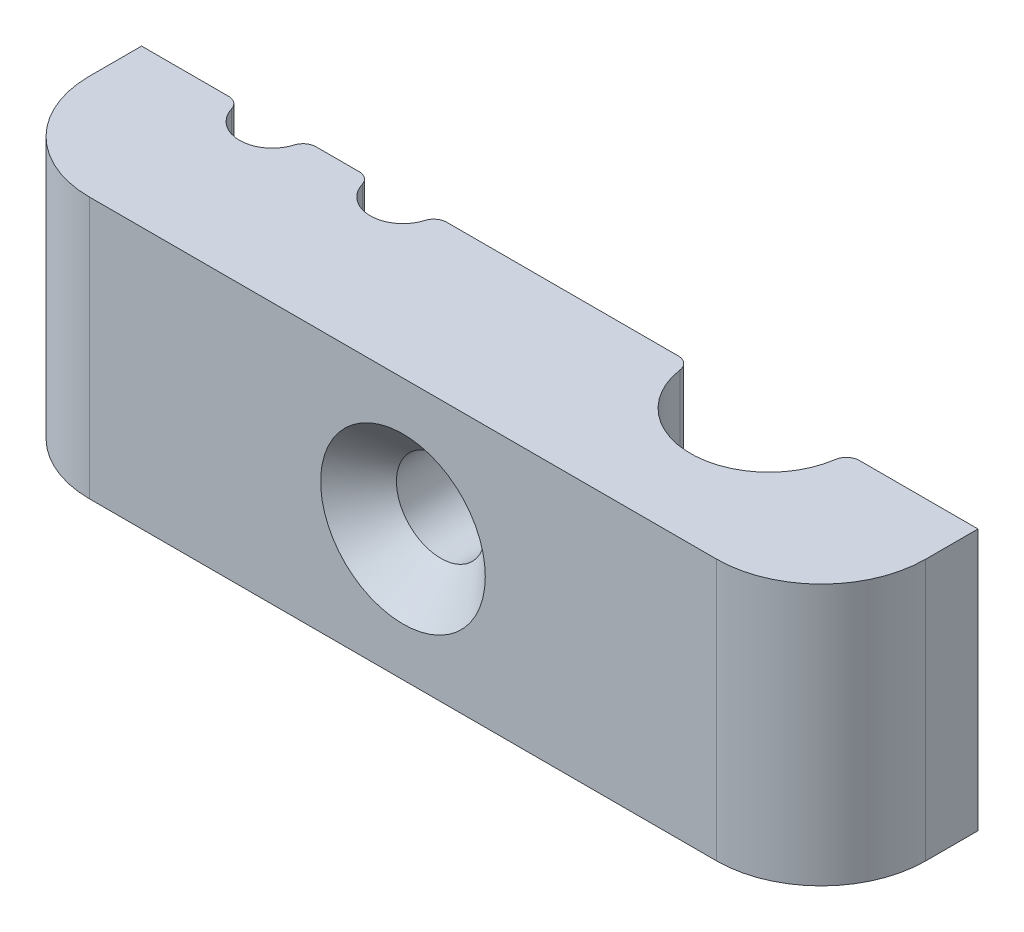
from build123d import *

# Parameters (mm, degrees)
SKETCH1_W               = 32
SKETCH1_H               = 10
BOSS_EXTRUDE1_DEPTH     = 6
FILLET1_R               = 4
SKETCH3_R               = 1.25
SKETCH3_R_2             = 3
CUT_EXTRUDE1_DEPTH      = 6
CUT_EXTRUDE1_DEPTH_BACK = 6
FILLET2_R               = 0.5


with BuildPart() as part:
    # Sketch1 → Boss-Extrude1 (new body)
    with BuildSketch(Plane.XY):
        Rectangle(SKETCH1_W, SKETCH1_H)
    extrude(amount=BOSS_EXTRUDE1_DEPTH)

    # Fillet1
    fillet1_edges = [part.edges().sort_by_distance(p)[0] for p in [
        (-16, 0, 6),
        (16, 0, 6),
    ]]
    fillet(fillet1_edges, radius=FILLET1_R)

    # Sketch2 → Cut-Revolve1 (revolve, cut)
    with BuildSketch(Plane(origin=(0, 0, 0), x_dir=(1, 0, 0), z_dir=(0, 1, 0))):
        Polygon((3.15, -6), (0, -6), (0, 0), (1.7, 0), (1.7, -4.55), align=None)
    revolve(axis=Axis((0, 0, 12.35), (0, 0, -1)), mode=Mode.SUBTRACT)

    # Sketch3 → Cut-Extrude1 (cut, two sides)
    with BuildSketch(Plane(origin=(0, 0, 0), x_dir=(1, 0, 0), z_dir=(0, 1, 0))) as cut_extrude1_sk:
        with Locations((-11, 0)):
            Circle(SKETCH3_R)
        with Locations((-6, 0)):
            Circle(SKETCH3_R)
        with Locations((8, 0)):
            Circle(SKETCH3_R_2)
    extrude(amount=CUT_EXTRUDE1_DEPTH, mode=Mode.SUBTRACT)
    extrude(cut_extrude1_sk.sketch, amount=-CUT_EXTRUDE1_DEPTH_BACK, mode=Mode.SUBTRACT)

    # Fillet2
    fillet2_edges = [part.edges().sort_by_distance(p)[0] for p in [
        (11, 0, 0),
        (5, 0, 0),
        (-4.75, 0, 0),
        (-7.25, 0, 0),
        (-9.75, 0, 0),
        (-12.25, 0, 0),
    ]]
    fillet(fillet2_edges, radius=FILLET2_R)


solid = part.part
